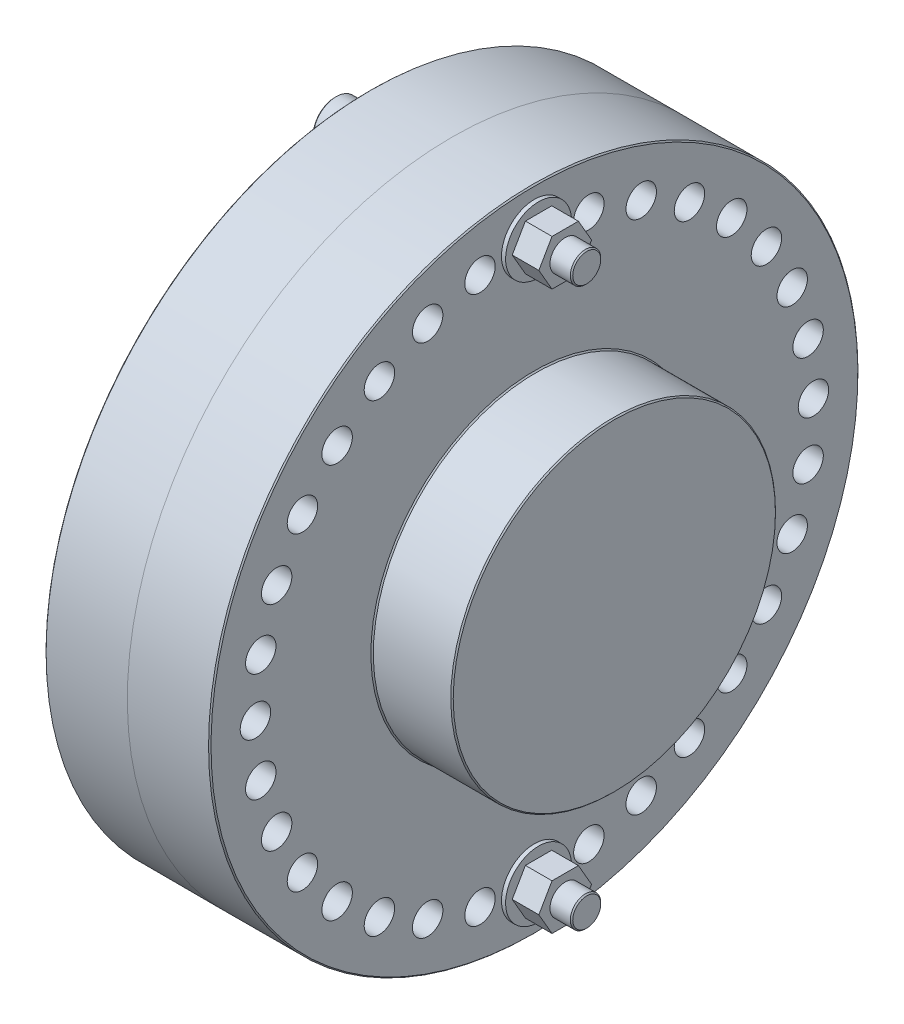
from build123d import *

# Parameters (mm, degrees)
CHAMFER2_SIZE       = 0.381
SKETCH2_R           = 4.7625
CUT_EXTRUDE1_DEPTH  = 77.596875
SKETCH3_R           = 4.7625
CUT_EXTRUDE2_DEPTH  = 77.596875
SKETCH4_R           = 10.31875
SKETCH4_R_2         = 5.159375
BOSS_EXTRUDE1_DEPTH = 1.2954
SKETCH5_R           = 7.1501
BOSS_EXTRUDE2_DEPTH = 9.525
CUT_EXTRUDE3_DEPTH  = 7.9375
SKETCH7_R           = 4.7625
BOSS_EXTRUDE4_DEPTH = 69.256275
SKETCH8_R           = 4.7625
BOSS_EXTRUDE5_DEPTH = 8.334375
CHAMFER1_SIZE       = 0.381


with BuildPart() as part:
    # Sketch1 → Revolve1 (revolve)
    with BuildSketch(Plane.XY):
        Polygon((0, 0), (0, 101.6), (-25.796875, 101.6), (-25.796875, 50.8), (-50.8, 50.8), (-50.8, 0), align=None)
    revolve(axis=Axis((0, 0, 0), (-1, 0, 0)))

    # Chamfer2
    chamfer2_edges = [part.edges().sort_by_distance(p)[0] for p in [
        (-50.8, -50.8, 0),
        (-25.796875, -50.8, 0),
        (-25.796875, -101.6, 0),
    ]]
    chamfer(chamfer2_edges, length=CHAMFER2_SIZE)


with BuildPart() as body_2:
    # Mirror1: mirrored copy
    add(part.part.mirror(Plane(origin=(0, 0, 0), x_dir=(0, 0, 1), z_dir=(1, 0, 0))))

    # Sketch3 → Cut-Extrude2 (cut, through all)
    with BuildSketch(Plane(origin=(25.796875, 0, 0), x_dir=(0, 0, -1), z_dir=(1, 0, 0))):
        with Locations(Location((0, 87.3125, 0), (0, 0, 90))):  # turned: the seam where the file's is
            Circle(SKETCH3_R)
        with Locations(Location((17.033823741, 85.634814795, 0), (0, 0, 90))):  # turned: the seam where the file's is
            Circle(SKETCH3_R)
        with Locations(Location((33.413047188, 80.666231682, 0), (0, 0, 90))):  # turned: the seam where the file's is
            Circle(SKETCH3_R)
        with Locations(Location((48.508225971, 72.597690524, 0), (0, 0, 90))):  # turned: the seam where the file's is
            Circle(SKETCH3_R)
        with Locations(Location((61.739260832, 61.739260832, 0), (0, 0, 90))):  # turned: the seam where the file's is
            Circle(SKETCH3_R)
        with Locations(Location((72.597690524, 48.508225971, 0), (0, 0, 90))):  # turned: the seam where the file's is
            Circle(SKETCH3_R)
        with Locations(Location((80.666231682, 33.413047188, 0), (0, 0, 90))):  # turned: the seam where the file's is
            Circle(SKETCH3_R)
        with Locations(Location((85.634814795, 17.033823741, 0), (0, 0, 90))):  # turned: the seam where the file's is
            Circle(SKETCH3_R)
        with Locations(Location((87.3125, 0, 0), (0, 0, 90))):  # turned: the seam where the file's is
            Circle(SKETCH3_R)
        with Locations(Location((85.634814795, -17.033823741, 0), (0, 0, 90))):  # turned: the seam where the file's is
            Circle(SKETCH3_R)
        with Locations(Location((80.666231682, -33.413047188, 0), (0, 0, 90))):  # turned: the seam where the file's is
            Circle(SKETCH3_R)
        with Locations(Location((72.597690524, -48.508225971, 0), (0, 0, 90))):  # turned: the seam where the file's is
            Circle(SKETCH3_R)
        with Locations(Location((61.739260832, -61.739260832, 0), (0, 0, 90))):  # turned: the seam where the file's is
            Circle(SKETCH3_R)
        with Locations(Location((48.508225971, -72.597690524, 0), (0, 0, 90))):  # turned: the seam where the file's is
            Circle(SKETCH3_R)
        with Locations(Location((33.413047188, -80.666231682, 0), (0, 0, 90))):  # turned: the seam where the file's is
            Circle(SKETCH3_R)
        with Locations(Location((17.033823741, -85.634814795, 0), (0, 0, 90))):  # turned: the seam where the file's is
            Circle(SKETCH3_R)
        with Locations(Location((0, -87.3125, 0), (0, 0, 90))):  # turned: the seam where the file's is
            Circle(SKETCH3_R)
        with Locations(Location((-17.033823741, -85.634814795, 0), (0, 0, 90))):  # turned: the seam where the file's is
            Circle(SKETCH3_R)
        with Locations(Location((-33.413047188, -80.666231682, 0), (0, 0, 90))):  # turned: the seam where the file's is
            Circle(SKETCH3_R)
        with Locations(Location((-48.508225971, -72.597690524, 0), (0, 0, 90))):  # turned: the seam where the file's is
            Circle(SKETCH3_R)
        with Locations(Location((-61.739260832, -61.739260832, 0), (0, 0, 90))):  # turned: the seam where the file's is
            Circle(SKETCH3_R)
        with Locations(Location((-72.597690524, -48.508225971, 0), (0, 0, 90))):  # turned: the seam where the file's is
            Circle(SKETCH3_R)
        with Locations(Location((-80.666231682, -33.413047188, 0), (0, 0, 90))):  # turned: the seam where the file's is
            Circle(SKETCH3_R)
        with Locations(Location((-85.634814795, -17.033823741, 0), (0, 0, 90))):  # turned: the seam where the file's is
            Circle(SKETCH3_R)
        with Locations(Location((-87.3125, 0, 0), (0, 0, 90))):  # turned: the seam where the file's is
            Circle(SKETCH3_R)
        with Locations(Location((-85.634814795, 17.033823741, 0), (0, 0, 90))):  # turned: the seam where the file's is
            Circle(SKETCH3_R)
        with Locations(Location((-80.666231682, 33.413047188, 0), (0, 0, 90))):  # turned: the seam where the file's is
            Circle(SKETCH3_R)
        with Locations(Location((-72.597690524, 48.508225971, 0), (0, 0, 90))):  # turned: the seam where the file's is
            Circle(SKETCH3_R)
        with Locations(Location((-61.739260832, 61.739260832, 0), (0, 0, 90))):  # turned: the seam where the file's is
            Circle(SKETCH3_R)
        with Locations(Location((-48.508225971, 72.597690524, 0), (0, 0, 90))):  # turned: the seam where the file's is
            Circle(SKETCH3_R)
        with Locations(Location((-33.413047188, 80.666231682, 0), (0, 0, 90))):  # turned: the seam where the file's is
            Circle(SKETCH3_R)
        with Locations(Location((-17.033823741, 85.634814795, 0), (0, 0, 90))):  # turned: the seam where the file's is
            Circle(SKETCH3_R)
    extrude(amount=-CUT_EXTRUDE2_DEPTH, mode=Mode.SUBTRACT)


with BuildPart() as part_1:
    add(part.part)

    # Sketch2 → Cut-Extrude1 (cut, through all)
    with BuildSketch(Plane.ZY.offset(25.796875)):
        with Locations(Location((0, 87.3125, 0), (0, 0, 270))):  # turned: the seam where the file's is
            Circle(SKETCH2_R)
        with Locations(Location((16.043629774, 85.825838766, 0), (0, 0, 270))):  # turned: the seam where the file's is
            Circle(SKETCH2_R)
        with Locations(Location((31.540912979, 81.41648153, 0), (0, 0, 270))):  # turned: the seam where the file's is
            Circle(SKETCH2_R)
        with Locations(Location((45.964108221, 74.234583663, 0), (0, 0, 270))):  # turned: the seam where the file's is
            Circle(SKETCH2_R)
        with Locations(Location((58.822050886, 64.524716085, 0), (0, 0, 270))):  # turned: the seam where the file's is
            Circle(SKETCH2_R)
        with Locations(Location((69.676879157, 52.617536689, 0), (0, 0, 270))):  # turned: the seam where the file's is
            Circle(SKETCH2_R)
        with Locations(Location((78.158944876, 38.918530189, 0), (0, 0, 270))):  # turned: the seam where the file's is
            Circle(SKETCH2_R)
        with Locations(Location((83.97940147, 23.894199821, 0), (0, 0, 270))):  # turned: the seam where the file's is
            Circle(SKETCH2_R)
        with Locations(Location((86.940040268, 8.056181136, 0), (0, 0, 270))):  # turned: the seam where the file's is
            Circle(SKETCH2_R)
        with Locations(Location((86.940040268, -8.056181136, 0), (0, 0, 270))):  # turned: the seam where the file's is
            Circle(SKETCH2_R)
        with Locations(Location((83.97940147, -23.894199821, 0), (0, 0, 270))):  # turned: the seam where the file's is
            Circle(SKETCH2_R)
        with Locations(Location((78.158944876, -38.918530189, 0), (0, 0, 270))):  # turned: the seam where the file's is
            Circle(SKETCH2_R)
        with Locations(Location((69.676879157, -52.617536689, 0), (0, 0, 270))):  # turned: the seam where the file's is
            Circle(SKETCH2_R)
        with Locations(Location((58.822050886, -64.524716085, 0), (0, 0, 270))):  # turned: the seam where the file's is
            Circle(SKETCH2_R)
        with Locations(Location((45.964108221, -74.234583663, 0), (0, 0, 270))):  # turned: the seam where the file's is
            Circle(SKETCH2_R)
        with Locations(Location((31.540912979, -81.41648153, 0), (0, 0, 270))):  # turned: the seam where the file's is
            Circle(SKETCH2_R)
        with Locations(Location((16.043629774, -85.825838766, 0), (0, 0, 270))):  # turned: the seam where the file's is
            Circle(SKETCH2_R)
        with Locations(Location((0, -87.3125, 0), (0, 0, 270))):  # turned: the seam where the file's is
            Circle(SKETCH2_R)
        with Locations(Location((-16.043629774, -85.825838766, 0), (0, 0, 270))):  # turned: the seam where the file's is
            Circle(SKETCH2_R)
        with Locations(Location((-31.540912979, -81.41648153, 0), (0, 0, 270))):  # turned: the seam where the file's is
            Circle(SKETCH2_R)
        with Locations(Location((-45.964108221, -74.234583663, 0), (0, 0, 270))):  # turned: the seam where the file's is
            Circle(SKETCH2_R)
        with Locations(Location((-58.822050886, -64.524716085, 0), (0, 0, 270))):  # turned: the seam where the file's is
            Circle(SKETCH2_R)
        with Locations(Location((-69.676879157, -52.617536689, 0), (0, 0, 270))):  # turned: the seam where the file's is
            Circle(SKETCH2_R)
        with Locations(Location((-78.158944876, -38.918530189, 0), (0, 0, 270))):  # turned: the seam where the file's is
            Circle(SKETCH2_R)
        with Locations(Location((-83.97940147, -23.894199821, 0), (0, 0, 270))):  # turned: the seam where the file's is
            Circle(SKETCH2_R)
        with Locations(Location((-86.940040268, -8.056181136, 0), (0, 0, 270))):  # turned: the seam where the file's is
            Circle(SKETCH2_R)
        with Locations(Location((-86.940040268, 8.056181136, 0), (0, 0, 270))):  # turned: the seam where the file's is
            Circle(SKETCH2_R)
        with Locations(Location((-83.97940147, 23.894199821, 0), (0, 0, 270))):  # turned: the seam where the file's is
            Circle(SKETCH2_R)
        with Locations(Location((-78.158944876, 38.918530189, 0), (0, 0, 270))):  # turned: the seam where the file's is
            Circle(SKETCH2_R)
        with Locations(Location((-69.676879157, 52.617536689, 0), (0, 0, 270))):  # turned: the seam where the file's is
            Circle(SKETCH2_R)
        with Locations(Location((-58.822050886, 64.524716085, 0), (0, 0, 270))):  # turned: the seam where the file's is
            Circle(SKETCH2_R)
        with Locations(Location((-45.964108221, 74.234583663, 0), (0, 0, 270))):  # turned: the seam where the file's is
            Circle(SKETCH2_R)
        with Locations(Location((-31.540912979, 81.41648153, 0), (0, 0, 270))):  # turned: the seam where the file's is
            Circle(SKETCH2_R)
        with Locations(Location((-16.043629774, 85.825838766, 0), (0, 0, 270))):  # turned: the seam where the file's is
            Circle(SKETCH2_R)
    extrude(amount=-CUT_EXTRUDE1_DEPTH, mode=Mode.SUBTRACT)


with BuildPart() as body_3:
    # Sketch4 → Boss-Extrude1 (new body)
    with BuildSketch(Plane.ZY.offset(25.796875)):
        with Locations(Location((0, 87.3125, 0), (0, 0, 270))):  # turned: the seam where the file's is
            Circle(SKETCH4_R)
        with Locations(Location((0, 87.3125, 0), (0, 0, 270))):  # turned: the seam where the file's is
            Circle(SKETCH4_R_2, mode=Mode.SUBTRACT)
    extrude(amount=BOSS_EXTRUDE1_DEPTH)


with BuildPart() as body_4:
    # Mirror2: mirrored copy
    add(body_3.part.mirror(Plane(origin=(0, 0, 0), x_dir=(0, 0, 1), z_dir=(1, 0, 0))))


with BuildPart() as body_5:
    # Sketch5 → Boss-Extrude2 (new body)
    with BuildSketch(Plane.ZY.offset(27.092275)):
        with Locations(Location((0, 87.3125, 0), (0, 0, 270))):  # turned: the seam where the file's is
            Circle(SKETCH5_R)
    extrude(amount=BOSS_EXTRUDE2_DEPTH)

    # Sketch6 → Cut-Extrude3 (cut)
    with BuildSketch(Plane.ZY.offset(36.617275)):
        Polygon((0, 82.729782238), (3.96875, 85.021141119), (3.96875, 89.603858881), (0, 91.895217762), (-3.96875, 89.603858881), (-3.96875, 85.021141119), align=None)
    extrude(amount=-CUT_EXTRUDE3_DEPTH, mode=Mode.SUBTRACT)

    # Sketch7 → Boss-Extrude4 (add)
    with BuildSketch(Plane(origin=(-27.092275, 0, 0), x_dir=(0, 0, -1), z_dir=(1, 0, 0))):
        with Locations(Location((0, 87.3125, 0), (0, 0, 270))):  # turned: the seam where the file's is
            Circle(SKETCH7_R)
    extrude(amount=BOSS_EXTRUDE4_DEPTH)

    # Chamfer1
    chamfer1_edges = [body_5.edges().sort_by_distance(p)[0] for p in [
        (42.164, 92.075, 0),
        (-36.617275, 94.4626, 0),
    ]]
    chamfer(chamfer1_edges, length=CHAMFER1_SIZE)


with BuildPart() as body_6:
    # Sketch8 → Boss-Extrude5 (new body)
    with BuildSketch(Plane(origin=(27.092275, 0, 0), x_dir=(0, 0, -1), z_dir=(1, 0, 0))):
        Polygon((4.124445986, 94.45625), (-4.124445986, 94.45625), (-8.248891971, 87.3125), (-4.124445986, 80.16875), (4.124445986, 80.16875), (8.248891971, 87.3125), align=None)
        with Locations(Location((0, 87.3125, 0), (0, 0, 90))):  # turned: the seam where the file's is
            Circle(SKETCH8_R, mode=Mode.SUBTRACT)
    extrude(amount=BOSS_EXTRUDE5_DEPTH)


with BuildPart() as body_7:
    # Mirror3: mirrored copy
    add(body_6.part.mirror(Plane.ZX))


with BuildPart() as body_8:
    # Mirror3 2: mirrored copy
    add(body_5.part.mirror(Plane.ZX))


with BuildPart() as body_9:
    # Mirror3 3: mirrored copy
    add(body_4.part.mirror(Plane.ZX))


with BuildPart() as body_10:
    # Mirror3 4: mirrored copy
    add(body_3.part.mirror(Plane.ZX))


solid = Compound([body_2.part, part_1.part, body_3.part, body_4.part, body_5.part, body_6.part, body_7.part, body_8.part, body_9.part, body_10.part])
